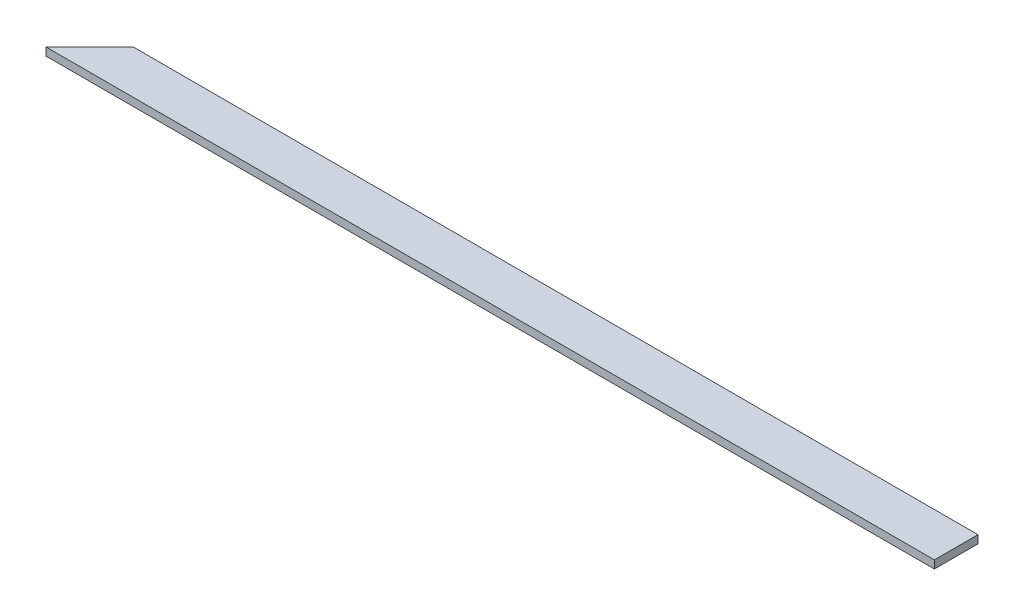
from build123d import *

# Parameters (mm, degrees)
BOSS_EXTRUDE1_DEPTH = 25.4


with BuildPart() as part:
    # Sketch1 → Boss-Extrude1 (new body)
    with BuildSketch(Plane(origin=(0, 0, 0), x_dir=(1, 0, 0), z_dir=(0, 1, 0))):
        Polygon((2844.8, 0), (2844.8, 139.7), (2705.1, 139.7), (139.7, 139.7), (0, 0), align=None)
    extrude(amount=BOSS_EXTRUDE1_DEPTH)


solid = part.part
